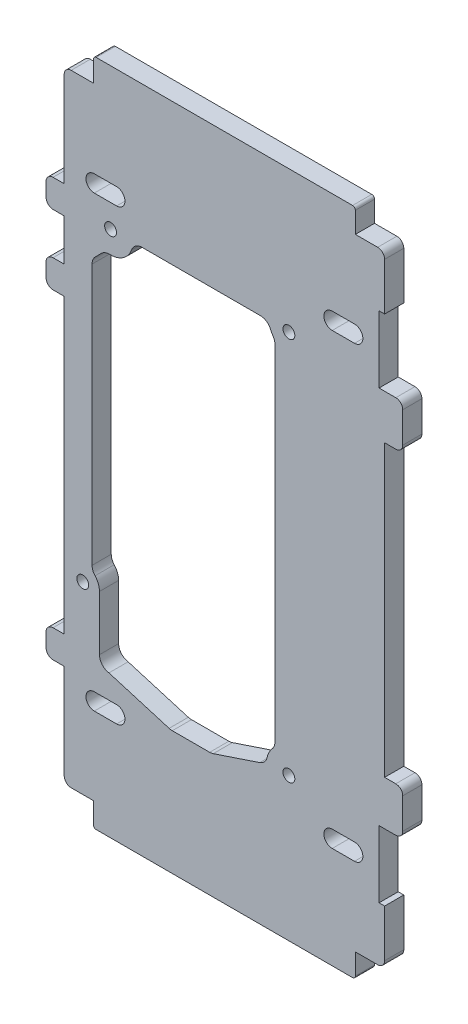
from build123d import *

# Parameters (mm, degrees)
SKETCH1_R           = 2.125
BOSS_EXTRUDE1_DEPTH = 6.88


with BuildPart() as part:
    # Sketch1 → Boss-Extrude1 (new body)
    with BuildSketch(Plane.XY):
        with BuildLine():
            Line((-78.364802088, -42.778869258), (-82.364802088, -42.778869258))
            ThreePointArc((-82.364802088, -42.778869258), (-84.132569041, -42.046636211), (-84.864802088, -40.278869258))
            Line((-84.864802088, -40.278869258), (-84.864802088, -35.278869258))
            ThreePointArc((-84.864802088, -35.278869258), (-84.132569041, -33.511102306), (-82.364802088, -32.778869258))
            Line((-82.364802088, -32.778869258), (-78.364802088, -32.778869258))
            Line((-78.364802088, -32.778869258), (-78.364802088, 72.221130742))
            Line((-78.364802088, 72.221130742), (-82.364802088, 72.221130742))
            ThreePointArc((-82.364802088, 72.221130742), (-84.132569041, 72.953363789), (-84.864802088, 74.721130742))
            Line((-84.864802088, 74.721130742), (-84.864802088, 79.721130742))
            ThreePointArc((-84.864802088, 79.721130742), (-84.132569041, 81.488897694), (-82.364802088, 82.221130742))
            Line((-82.364802088, 82.221130742), (-78.364802088, 82.221130742))
            Line((-78.364802088, 82.221130742), (-78.364802088, 97.221130742))
            Line((-78.364802088, 97.221130742), (-82.364802088, 97.221130742))
            ThreePointArc((-82.364802088, 97.221130742), (-84.132569041, 97.953363789), (-84.864802088, 99.721130742))
            Line((-84.864802088, 99.721130742), (-84.864802088, 104.721130742))
            ThreePointArc((-84.864802088, 104.721130742), (-84.132569041, 106.488897694), (-82.364802088, 107.221130742))
            Line((-82.364802088, 107.221130742), (-78.364802088, 107.221130742))
            Line((-78.364802088, 107.221130742), (-78.364802088, 141.221127314))
            ThreePointArc((-78.364802088, 141.221127314), (-77.632570253, 142.988896483), (-75.864802088, 143.721130742))
            Line((-75.864802088, 143.721130742), (-67.864802088, 143.721130742))
            Line((-67.864802088, 143.721130742), (-67.864802088, 151.221130742))
            ThreePointArc((-67.864802088, 151.221130742), (-67.571908869, 151.928237523), (-66.864802088, 152.221130742))
            Line((-66.864802088, 152.221130742), (25.135197912, 152.221130742))
            ThreePointArc((25.135197912, 152.221130742), (25.842304693, 151.928237523), (26.135197912, 151.221130742))
            Line((26.135197912, 151.221130742), (26.135197912, 143.721130742))
            Line((26.135197912, 143.721130742), (34.135197912, 143.721130742))
            ThreePointArc((34.135197912, 143.721130742), (35.902964865, 142.988897694), (36.635197912, 141.221130742))
            Line((36.635197912, 141.221130742), (36.635197912, 124.221130742))
            Line((36.635197912, 124.221130742), (34.635197912, 124.221130742))
            Line((34.635197912, 124.221130742), (34.635197912, 100.221130742))
            Line((34.635197912, 100.221130742), (40.635197912, 100.221130742))
            ThreePointArc((40.635197912, 100.221130742), (42.402964865, 99.488897694), (43.135197912, 97.721130742))
            Line((43.135197912, 97.721130742), (43.135197912, 86.721130742))
            ThreePointArc((43.135197912, 86.721130742), (42.402964865, 84.953363789), (40.635197912, 84.221130742))
            Line((40.635197912, 84.221130742), (36.635197912, 84.221130742))
            Line((36.635197912, 84.221130742), (36.635197912, -19.778869258))
            Line((36.635197912, -19.778869258), (40.635197912, -19.778869258))
            ThreePointArc((40.635197912, -19.778869258), (42.402964865, -20.511102306), (43.135197912, -22.278869258))
            Line((43.135197912, -22.278869258), (43.135197912, -33.278869258))
            ThreePointArc((43.135197912, -33.278869258), (42.402964865, -35.046636211), (40.635197912, -35.778869258))
            Line((40.635197912, -35.778869258), (34.635197912, -35.778869258))
            Line((34.635197912, -35.778869258), (34.635197912, -59.778869258))
            Line((34.635197912, -59.778869258), (36.635197912, -59.778869258))
            Line((36.635197912, -59.778869258), (36.635197912, -76.778869258))
            ThreePointArc((36.635197912, -76.778869258), (35.902964865, -78.546636211), (34.135197912, -79.278869258))
            Line((34.135197912, -79.278869258), (26.135197912, -79.278869258))
            Line((26.135197912, -79.278869258), (26.135197912, -86.778869258))
            ThreePointArc((26.135197912, -86.778869258), (25.842304693, -87.48597604), (25.135197912, -87.778869258))
            Line((25.135197912, -87.778869258), (-66.864802088, -87.778869258))
            ThreePointArc((-66.864802088, -87.778869258), (-67.571908869, -87.48597604), (-67.864802088, -86.778869258))
            Line((-67.864802088, -86.778869258), (-67.864802088, -79.278869258))
            Line((-67.864802088, -79.278869258), (-75.864802088, -79.278869258))
            ThreePointArc((-75.864802088, -79.278869258), (-77.632569041, -78.546636211), (-78.364802088, -76.778869258))
            Line((-78.364802088, -76.778869258), (-78.364802088, -42.778869258))
        make_face()
        with Locations((-71.704802088, -13.178869258)):
            Circle(SKETCH1_R, mode=Mode.SUBTRACT)
        with Locations((2.277397912, 101.421130742)):
            Circle(SKETCH1_R, mode=Mode.SUBTRACT)
        with Locations((-61.722602088, 101.421130741)):
            Circle(SKETCH1_R, mode=Mode.SUBTRACT)
        with Locations((2.277397912, -36.378869258)):
            Circle(SKETCH1_R, mode=Mode.SUBTRACT)
        with BuildLine():
            Line((17.827855969, -45.278869258), (25.827855969, -45.278869258))
            ThreePointArc((25.827855969, -45.278869258), (28.827855969, -48.278869258), (25.827855969, -51.278869258))
            Line((25.827855969, -51.278869258), (17.827855969, -51.278869258))
            ThreePointArc((17.827855969, -51.278869258), (14.827855969, -48.278869258), (17.827855969, -45.278869258))
        make_face(mode=Mode.SUBTRACT)
        with BuildLine():
            Line((-65.704802088, -13.178869258), (-65.704802088, -32.824689972))
            ThreePointArc((-65.704802088, -32.824689972), (-64.73917528, -35.430947697), (-62.308512422, -36.778869258))
            Line((-62.308512422, -36.778869258), (-40.709388186, -43.22032523))
            ThreePointArc((-40.709388186, -43.22032523), (-40.143864213, -43.345228063), (-39.566230949, -43.387155324))
            Line((-39.566230949, -43.387155324), (-26.151305592, -43.387155324))
            ThreePointArc((-26.151305592, -43.387155324), (-25.50948768, -43.33532829), (-24.884301528, -43.181190208))
            Line((-24.884301528, -43.181190208), (-8.176926635, -37.601823511))
            ThreePointArc((-8.176926635, -37.601823511), (-6.469142152, -36.4818554), (-5.536821161, -34.664815504))
            ThreePointArc((-5.536821161, -34.664815504), (-4.857565105, -32.760540535), (-3.722602088, -31.087366636))
            ThreePointArc((-3.722602088, -31.087366636), (-2.980944701, -29.855828888), (-2.722602088, -28.441615325))
            Line((-2.722602088, -28.441615325), (-2.722602088, 95.096575421))
            ThreePointArc((-2.722602088, 95.096575421), (-2.908751731, 96.3026208), (-3.449874815, 97.396413719))
            ThreePointArc((-3.449874815, 97.396413719), (-3.891134752, 98.112172481), (-4.243388939, 98.875676196))
            ThreePointArc((-4.243388939, 98.875676196), (-5.713248555, 100.724022037), (-7.969552854, 101.421130741))
            Line((-7.969552854, 101.421130741), (-50.408893589, 101.421130741))
            ThreePointArc((-50.408893589, 101.421130741), (-52.718294666, 100.687117065), (-54.180129755, 98.754464075))
            ThreePointArc((-54.180129755, 98.754464075), (-57.229450027, 94.802098746), (-62.028259496, 93.426972027))
            ThreePointArc((-62.028259496, 93.426972027), (-63.640931937, 93.153984004), (-65.009515325, 92.258319795))
            Line((-65.009515325, 92.258319795), (-67.193229213, 90.074605907))
            ThreePointArc((-67.193229213, 90.074605907), (-68.060320218, 88.776912512), (-68.364802088, 87.246178782))
            Line((-68.364802088, 87.246178782), (-68.364802088, -6.387374578))
            ThreePointArc((-68.364802088, -6.387374578), (-68.089315479, -7.84614118), (-67.300802088, -9.10397245))
            ThreePointArc((-67.300802088, -9.10397245), (-66.118032001, -10.990719355), (-65.704802088, -13.178869258))
        make_face(mode=Mode.SUBTRACT)
        with BuildLine():
            Line((-67.557460145, 109.721130742), (-59.557460145, 109.721130742))
            ThreePointArc((-59.557460145, 109.721130742), (-56.557460145, 112.721130742), (-59.557460145, 115.721130742))
            Line((-59.557460145, 115.721130742), (-67.557460145, 115.721130742))
            ThreePointArc((-67.557460145, 115.721130742), (-70.557460145, 112.721130742), (-67.557460145, 109.721130742))
        make_face(mode=Mode.SUBTRACT)
        with BuildLine():
            Line((17.827855969, 109.721130742), (25.827855969, 109.721130742))
            ThreePointArc((25.827855969, 109.721130742), (28.827855969, 112.721130742), (25.827855969, 115.721130742))
            Line((25.827855969, 115.721130742), (17.827855969, 115.721130742))
            ThreePointArc((17.827855969, 115.721130742), (14.827855969, 112.721130742), (17.827855969, 109.721130742))
        make_face(mode=Mode.SUBTRACT)
        with BuildLine():
            Line((-67.557460145, -45.278869258), (-59.557460145, -45.278869258))
            ThreePointArc((-59.557460145, -45.278869258), (-56.557460145, -48.278869258), (-59.557460145, -51.278869258))
            Line((-59.557460145, -51.278869258), (-67.557460145, -51.278869258))
            ThreePointArc((-67.557460145, -51.278869258), (-70.557460145, -48.278869258), (-67.557460145, -45.278869258))
        make_face(mode=Mode.SUBTRACT)
    extrude(amount=BOSS_EXTRUDE1_DEPTH)


solid = part.part
